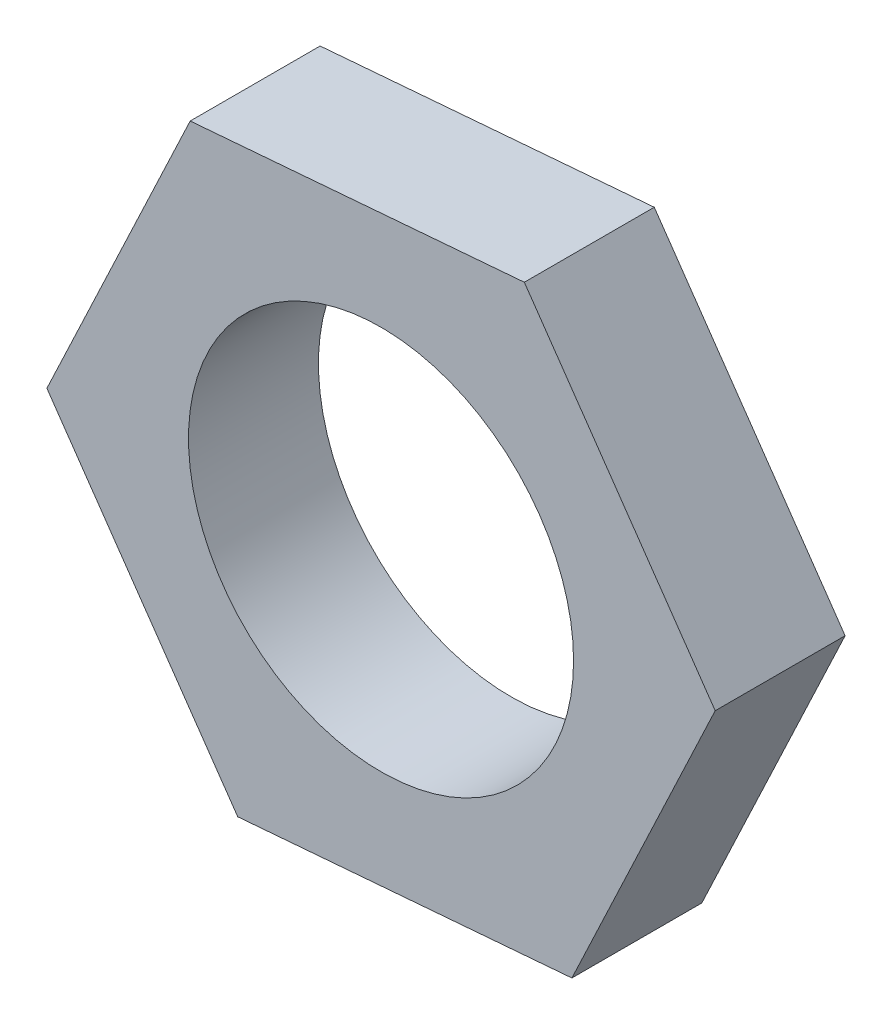
from build123d import *

# Parameters (mm, degrees)
DODANIE_WYCI_GNI_CIE1_DEPTH = 3.1
SZKIC4_R                    = 4.594
WYTNIJ_WYCI_GNI_CIE1_DEPTH  = 3.1


with BuildPart() as part:
    # Szkic1 → Dodanie-wyciągnięcie1 (new body)
    with BuildSketch(Plane.XY):
        Polygon((-4.553889676, 6.57739225), (-7.973133618, -0.655088021), (-3.419243941, -7.232480271), (4.553889676, -6.57739225), (7.973133618, 0.655088021), (3.419243941, 7.232480271), align=None)
    extrude(amount=DODANIE_WYCI_GNI_CIE1_DEPTH)

    # Szkic4 → Wytnij-wyciągnięcie1 (cut)
    with BuildSketch(Plane.XY.offset(3.1)):
        Circle(SZKIC4_R)
    extrude(amount=-WYTNIJ_WYCI_GNI_CIE1_DEPTH, mode=Mode.SUBTRACT)


solid = part.part
